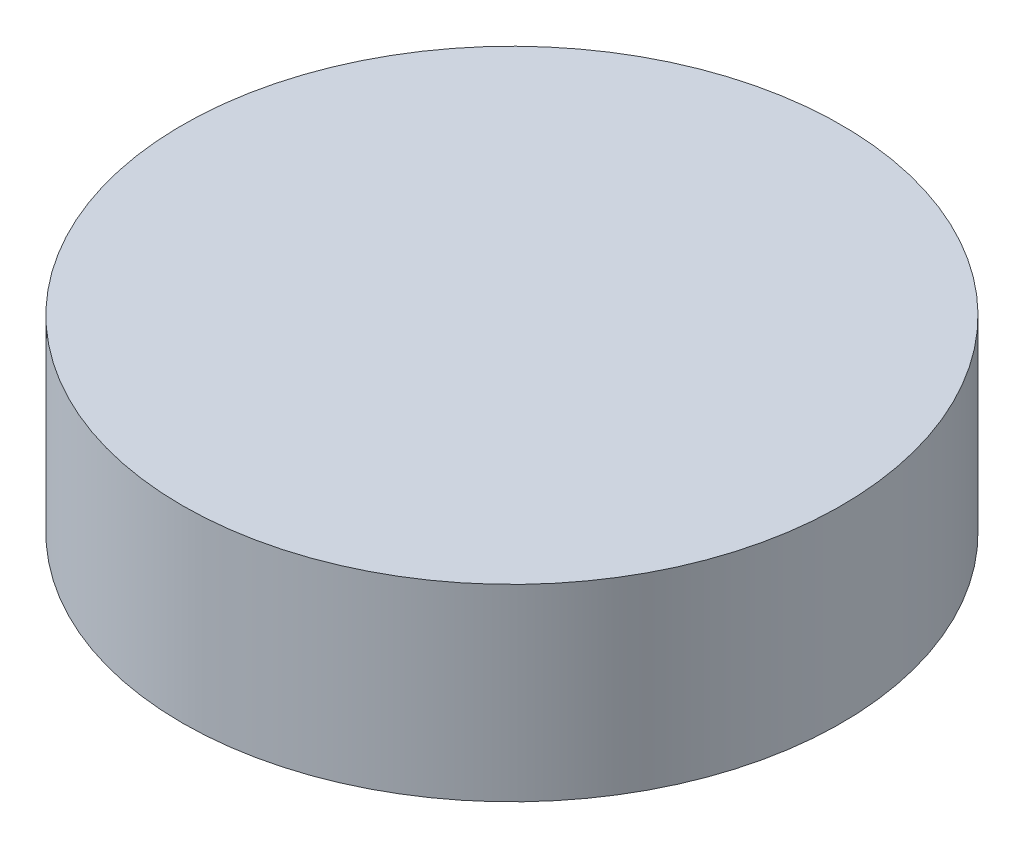
from build123d import *

# Parameters (mm, degrees)
SKETCH_1_R      = 17.5
EXTRUDE_1_DEPTH = 10


with BuildPart() as part:
    # 草图1 → 凸台-拉伸1 (new body)
    with BuildSketch(Plane(origin=(0, 0, 0), x_dir=(1, 0, 0), z_dir=(0, 1, 0))):
        Circle(SKETCH_1_R)
    extrude(amount=EXTRUDE_1_DEPTH)


solid = part.part
